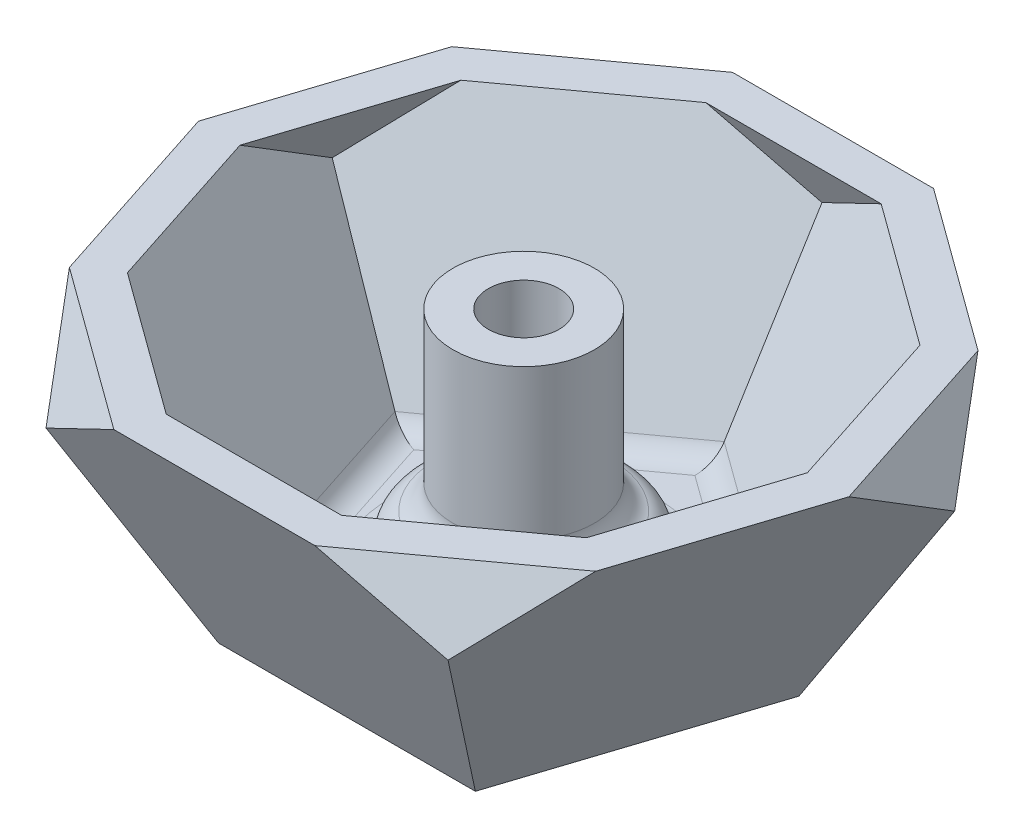
from build123d import *

# Parameters (mm, degrees)
BOSS_EXTRUDE1_DEPTH     = 30
BOSS_EXTRUDE1_TAPER     = -26.56505118
SKETCH3_OUTSIDE_W       = 108.076
SKETCH3_OUTSIDE_H       = 105.2
CUT_EXTRUDE1_DEPTH      = 30
CUT_EXTRUDE1_TAPER      = 26.56505118
SKETCH5_R               = 19.347524159
CUT_EXTRUDE2_DEPTH      = 25
SHELL1_T                = -2
SKETCH6_R               = 4
SKETCH6_R_2             = 2
BOSS_EXTRUDE2_DEPTH     = 13
SKETCH10_R              = 6
SKETCH10_R_2            = 4
BOSS_EXTRUDE4_DEPTH     = 3
FILLET5_R               = 1.5
SKETCH10_3_R            = 4.5
SKETCH10_3_R_2          = 4
CUT_EXTRUDE3_DEPTH      = 2
CUT_EXTRUDE3_DEPTH_BACK = 2
FILLET6_R               = 1.5


with BuildPart() as part:
    # Sketch1 → Boss-Extrude1 (new body)
    with BuildSketch(Plane(origin=(0, 0, 0), x_dir=(1, 0, 0), z_dir=(0, 1, 0))):
        Polygon((0, 12.360679775), (-11.755705046, 3.819660113), (-7.26542528, -10), (7.26542528, -10), (11.755705046, 3.819660113), align=None)
    extrude(amount=BOSS_EXTRUDE1_DEPTH, taper=BOSS_EXTRUDE1_TAPER)

    # Sketch3 outside → Cut-Extrude1 (cut)
    with BuildSketch(Plane(origin=(0, 30, 0), x_dir=(1, 0, 0), z_dir=(0, 1, 0))):
        with Locations((0, 2.951)):
            Rectangle(SKETCH3_OUTSIDE_W, SKETCH3_OUTSIDE_H)
        Polygon((7.26542528, 10), (-7.26542528, 10), (-11.755705046, -3.819660113), (0, -12.360679775), (11.755705046, -3.819660113), align=None, mode=Mode.SUBTRACT)
    extrude(amount=-CUT_EXTRUDE1_DEPTH, taper=CUT_EXTRUDE1_TAPER, mode=Mode.SUBTRACT)

    # Sketch5 → Cut-Extrude2 (cut)
    with BuildSketch(Plane(origin=(0, 15, 0), x_dir=(1, 0, 0), z_dir=(0, 1, 0))):
        Circle(SKETCH5_R)
    extrude(amount=CUT_EXTRUDE2_DEPTH, mode=Mode.SUBTRACT)

    # Shell1
    shell1_openings = [part.faces().sort_by_distance(p)[0] for p in [
        (0, 15, 0),
    ]]
    offset(amount=SHELL1_T, openings=shell1_openings, kind=Kind.INTERSECTION)

    # Sketch6 → Boss-Extrude2 (add)
    with BuildSketch(Plane(origin=(0, 2, 0), x_dir=(1, 0, 0), z_dir=(0, 1, 0))):
        with Locations(Location((0, 0, 0), (0, 0, 270))):
            Circle(SKETCH6_R)
        with Locations(Location((0, 0, 0), (0, 0, 270))):
            Circle(SKETCH6_R_2, mode=Mode.SUBTRACT)
    extrude(amount=BOSS_EXTRUDE2_DEPTH)

    # Sketch10 → Boss-Extrude4 (add)
    with BuildSketch(Plane(origin=(0, 2, 0), x_dir=(1, 0, 0), z_dir=(0, 1, 0))):
        with Locations(Location((0, 0, 0), (0, 0, 270))):
            Circle(SKETCH10_R)
        with Locations(Location((0, 0, 0), (0, 0, 270))):
            Circle(SKETCH10_R_2, mode=Mode.SUBTRACT)
    extrude(amount=BOSS_EXTRUDE4_DEPTH)

    # Fillet5
    fillet5_edges = [part.edges().sort_by_distance(p)[0] for p in [
        (0, 2, -6),
        (0, 5, -4),
        (5.151309995, 2, -7.090169944),
        (-5.151309995, 2, -7.090169944),
        (-8.334994658, 2, 2.708203933),
        (0, 2, 8.763932023),
        (8.334994658, 2, 2.708203933),
    ]]
    fillet(fillet5_edges, radius=FILLET5_R)

    # Sketch10_3 → Cut-Extrude3 (cut, two sides)
    with BuildSketch(Plane(origin=(0, 2, 0), x_dir=(1, 0, 0), z_dir=(0, 1, 0))) as cut_extrude3_sk:
        with Locations(Location((0, 0, 0), (0, 0, 270))):
            Circle(SKETCH10_3_R)
        with Locations(Location((0, 0, 0), (0, 0, 270))):
            Circle(SKETCH10_3_R_2, mode=Mode.SUBTRACT)
        with Locations(Location((0, 0, 0), (0, 0, 270))):
            Circle(SKETCH10_3_R_2)
    extrude(amount=CUT_EXTRUDE3_DEPTH, mode=Mode.SUBTRACT)
    extrude(cut_extrude3_sk.sketch, amount=-CUT_EXTRUDE3_DEPTH_BACK, mode=Mode.SUBTRACT)

    # Fillet6
    fillet6_edges = [part.edges().sort_by_distance(p)[0] for p in [
        (0, 4, -4.5),
        (0, 5, -6),
    ]]
    fillet(fillet6_edges, radius=FILLET6_R)


solid = part.part
